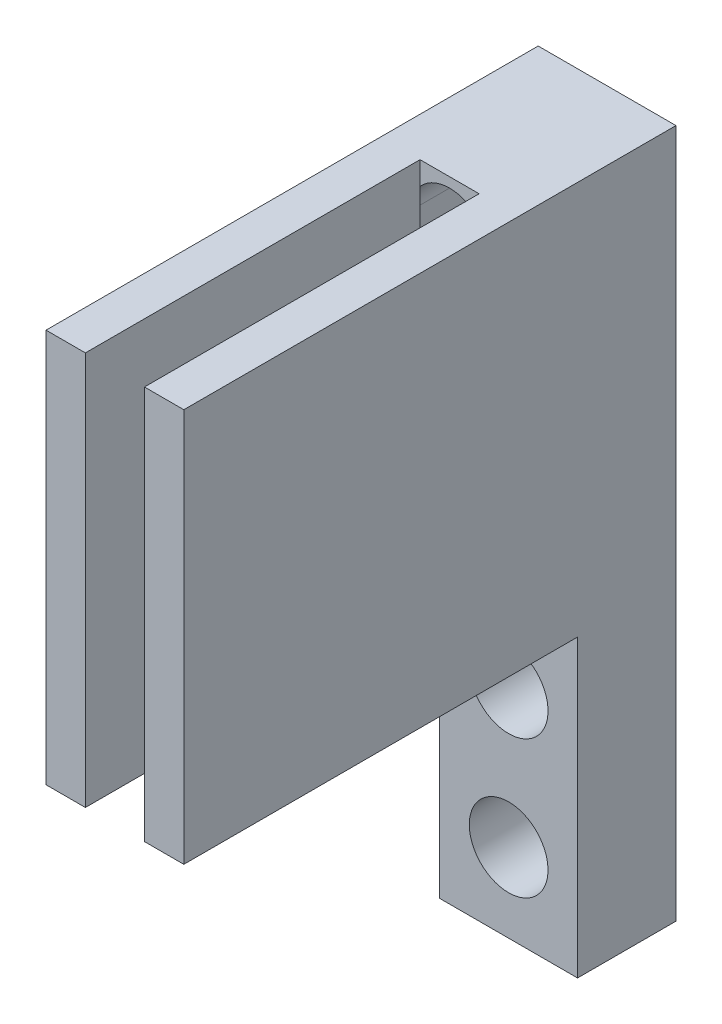
from build123d import *

# Parameters (mm, degrees)
BOSS_EXTRUDE1_DEPTH = 20
CUT_EXTRUDE3_DEPTH  = 8
SKETCH4_W           = 7
SKETCH4_H           = 15
SKETCH4_R           = 2
BOSS_EXTRUDE2_DEPTH = 5


with BuildPart() as part:
    # Sketch1 → Boss-Extrude1 (new body)
    with BuildSketch(Plane(origin=(0, 0, 0), x_dir=(1, 0, 0), z_dir=(0, 1, 0))):
        Polygon((-1.5, -12.5), (-1.5, 4.5), (1.5, 4.5), (1.5, -12.5), (3.5, -12.5), (3.5, 12.5), (-3.5, 12.5), (-3.5, -12.5), align=None)
    extrude(amount=BOSS_EXTRUDE1_DEPTH)

    # Sketch2 → Cut-Extrude3 (cut)
    with BuildSketch(Plane.XY.offset(-4.5)):
        with BuildLine():
            Line((2, 17.5), (2, 10.5))
            ThreePointArc((2, 10.5), (0, 8.5), (-2, 10.5))
            Line((-2, 10.5), (-2, 17.5))
            ThreePointArc((-2, 17.5), (0, 19.5), (2, 17.5))
        make_face()
    extrude(amount=-CUT_EXTRUDE3_DEPTH, mode=Mode.SUBTRACT)

    # Sketch4 → Boss-Extrude2 (add)
    with BuildSketch(Plane(origin=(0, 0, -12.5), x_dir=(-1, 0, 0), z_dir=(0, 0, -1))):
        with Locations((0, -7.5)):
            Rectangle(SKETCH4_W, SKETCH4_H)
        with Locations((0, -4)):
            Circle(SKETCH4_R, mode=Mode.SUBTRACT)
        with Locations((0, -11)):
            Circle(SKETCH4_R, mode=Mode.SUBTRACT)
    extrude(amount=-BOSS_EXTRUDE2_DEPTH)


solid = part.part
